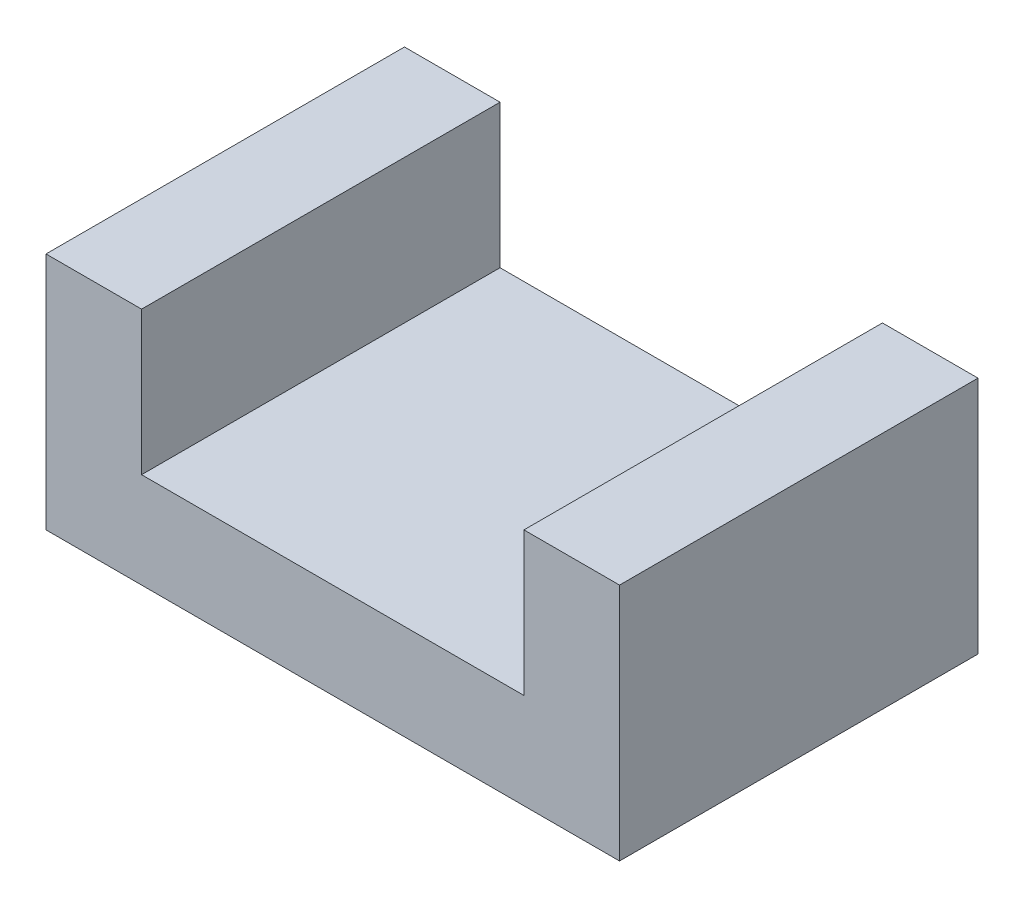
from build123d import *

# Parameters (mm, degrees)
SKETCH1_W           = 24
SKETCH1_H           = 15
BOSS_EXTRUDE1_DEPTH = 4
SKETCH2_W           = 4
SKETCH2_H           = 15
BOSS_EXTRUDE2_DEPTH = 6


with BuildPart() as part:
    # Sketch1 → Boss-Extrude1 (new body)
    with BuildSketch(Plane(origin=(0, 0, 0), x_dir=(1, 0, 0), z_dir=(0, 1, 0))):
        with Locations((12, 7.5)):
            Rectangle(SKETCH1_W, SKETCH1_H)
    extrude(amount=BOSS_EXTRUDE1_DEPTH)

    # Sketch2 → Boss-Extrude2 (add)
    with BuildSketch(Plane(origin=(0, 4, 0), x_dir=(1, 0, 0), z_dir=(0, 1, 0))):
        with Locations((2, 7.5)):
            Rectangle(SKETCH2_W, SKETCH2_H)
        with Locations((22, 7.5)):
            Rectangle(SKETCH2_W, SKETCH2_H)
    extrude(amount=BOSS_EXTRUDE2_DEPTH)


solid = part.part
